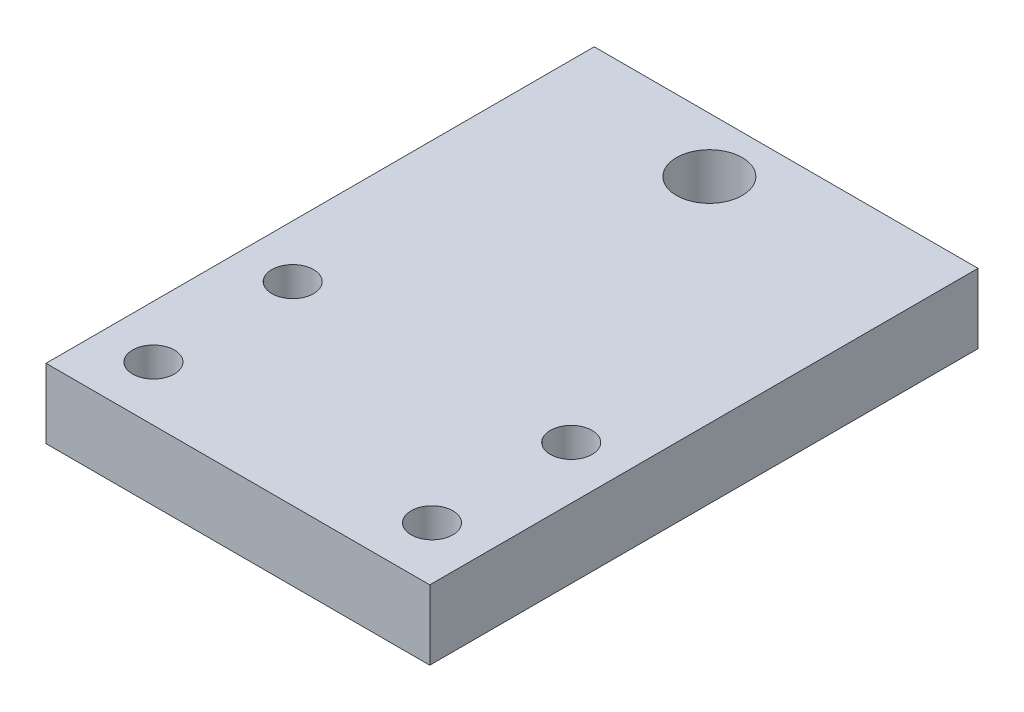
from build123d import *

# Parameters (mm, degrees)
SKETCH1_W           = 35
SKETCH1_H           = 50
SKETCH1_R           = 3
SKETCH1_R_2         = 1.905
BOSS_EXTRUDE1_DEPTH = 6.35


with BuildPart() as part:
    # Sketch1 → Boss-Extrude1 (new body)
    with BuildSketch(Plane(origin=(0, 0, 0), x_dir=(1, 0, 0), z_dir=(0, 1, 0))):
        with Locations((17.5, 25)):
            Rectangle(SKETCH1_W, SKETCH1_H)
        with Locations((15.5, 45)):
            Circle(SKETCH1_R, mode=Mode.SUBTRACT)
        with Locations((4.8, 5)):
            Circle(SKETCH1_R_2, mode=Mode.SUBTRACT)
        with Locations((30.2, 5)):
            Circle(SKETCH1_R_2, mode=Mode.SUBTRACT)
        with Locations((4.8, 17.7)):
            Circle(SKETCH1_R_2, mode=Mode.SUBTRACT)
        with Locations((30.2, 17.7)):
            Circle(SKETCH1_R_2, mode=Mode.SUBTRACT)
    extrude(amount=BOSS_EXTRUDE1_DEPTH)


solid = part.part
